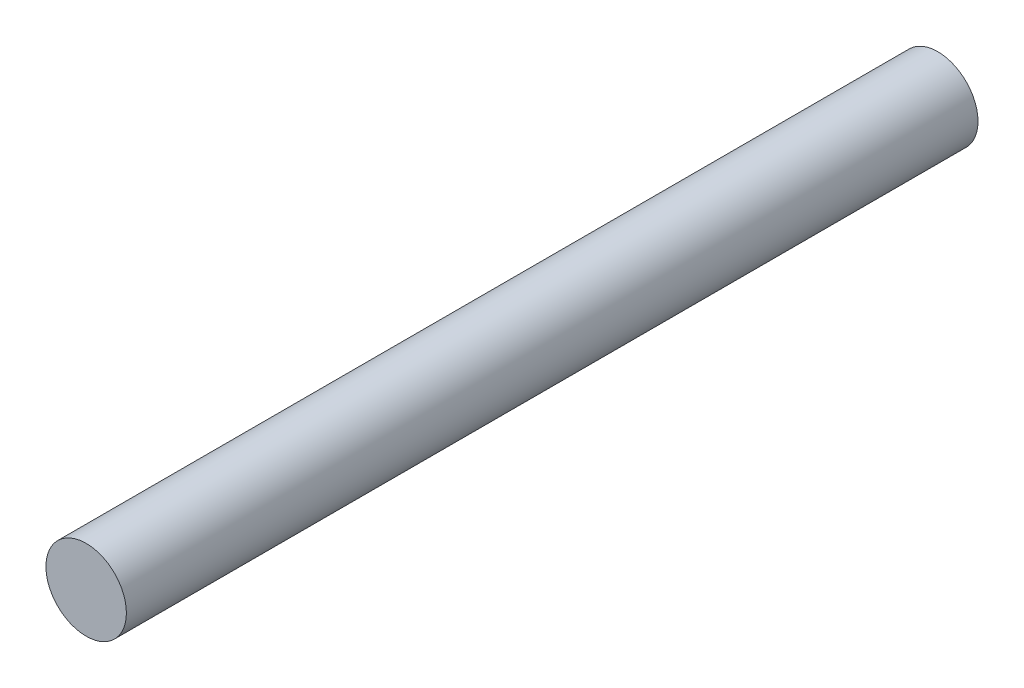
from build123d import *

# Parameters (mm, degrees)
SKETCH1_R           = 3
BOSS_EXTRUDE1_DEPTH = 63.5


with BuildPart() as part:
    # Sketch1 → Boss-Extrude1 (new body)
    with BuildSketch(Plane.XY):
        Circle(SKETCH1_R)
    extrude(amount=BOSS_EXTRUDE1_DEPTH)


solid = part.part
